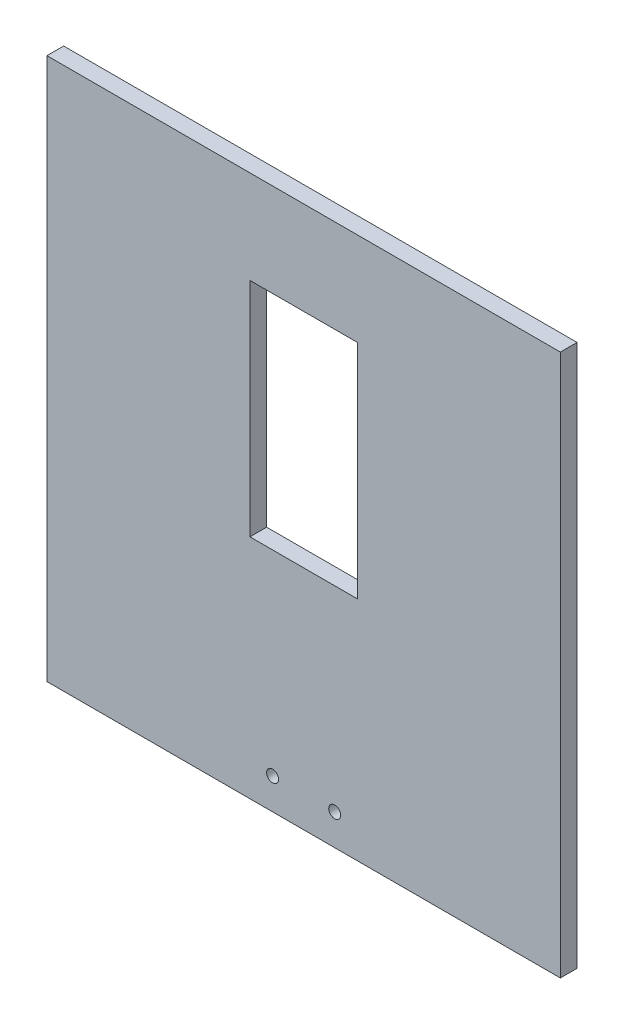
from build123d import *

# Parameters (mm, degrees)
SKETCH1_W           = 215
SKETCH1_H           = 227
SKETCH1_R           = 2.5
SKETCH1_W_2         = 45
SKETCH1_H_2         = 93
BOSS_EXTRUDE1_DEPTH = 7


with BuildPart() as part:
    # Sketch1 → Boss-Extrude1 (new body)
    with BuildSketch(Plane.XY):
        with Locations((0, 3.089375999)):
            Rectangle(SKETCH1_W, SKETCH1_H)
        with Locations((-13, -97.410624001)):
            Circle(SKETCH1_R, mode=Mode.SUBTRACT)
        with Locations((13, -97.410624001)):
            Circle(SKETCH1_R, mode=Mode.SUBTRACT)
        with Locations((0, 31.089375999)):
            Rectangle(SKETCH1_W_2, SKETCH1_H_2, mode=Mode.SUBTRACT)
    extrude(amount=BOSS_EXTRUDE1_DEPTH)


solid = part.part
